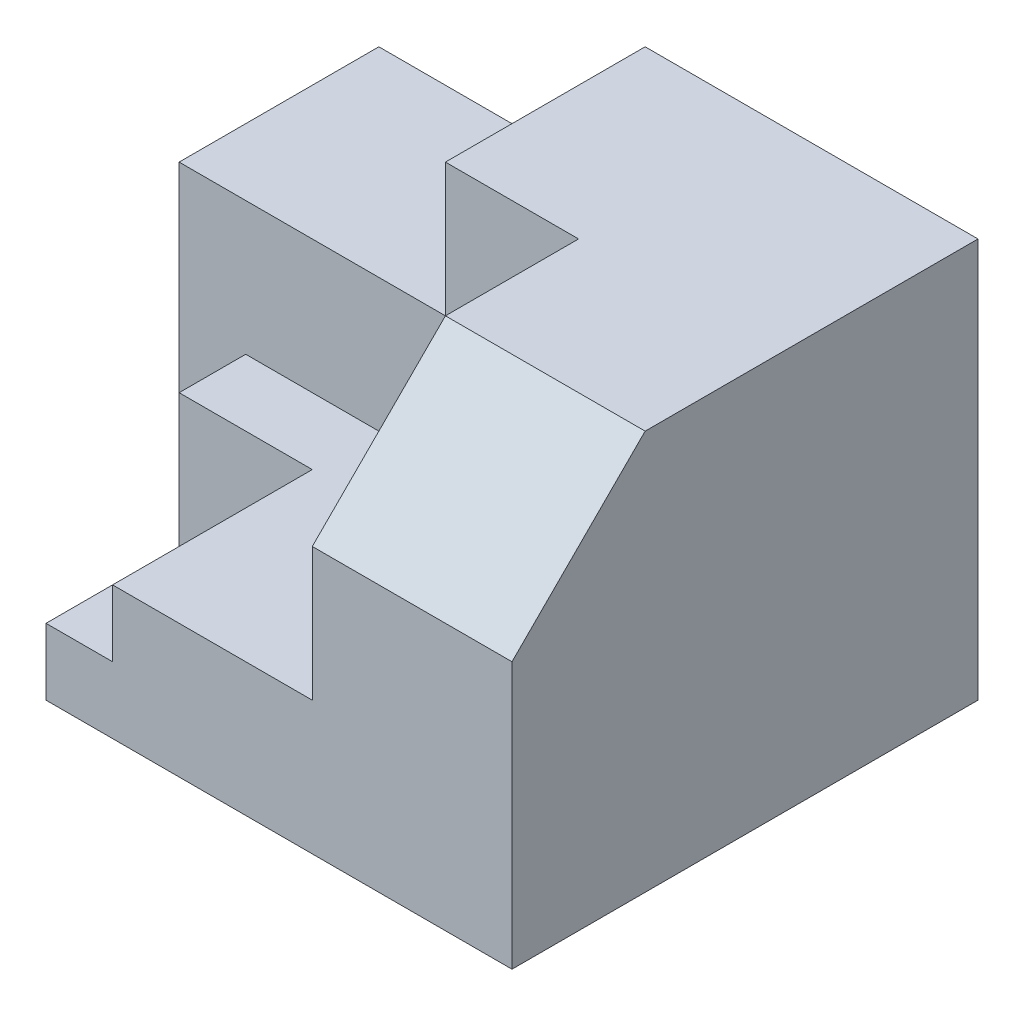
from build123d import *

# Parameters (mm, degrees)
SKETCH1_W           = 90
SKETCH1_H           = 70
BOSS_EXTRUDE1_DEPTH = 60
SKETCH2_W           = 60
SKETCH2_H           = 40
CUT_EXTRUDE1_DEPTH  = 40
SKETCH3_W           = 30
SKETCH3_H           = 30
CUT_EXTRUDE2_DEPTH  = 10
SKETCH4_W           = 30
SKETCH4_H           = 10
CUT_EXTRUDE3_DEPTH  = 20
SKETCH5_W           = 10
SKETCH5_H           = 20
CUT_EXTRUDE4_DEPTH  = 10
SKETCH7_W           = 40
SKETCH7_H           = 30
CUT_EXTRUDE5_DEPTH  = 20
CHAMFER1_SIZE       = 20


with BuildPart() as part:
    # Sketch1 → Boss-Extrude1 (new body)
    with BuildSketch(Plane(origin=(0, 0, 0), x_dir=(1, 0, 0), z_dir=(0, 1, 0))):
        with Locations((45, 35)):
            Rectangle(SKETCH1_W, SKETCH1_H)
    extrude(amount=BOSS_EXTRUDE1_DEPTH)

    # Sketch2 → Cut-Extrude1 (cut)
    with BuildSketch(Plane(origin=(0, 60, 0), x_dir=(1, 0, 0), z_dir=(0, 1, 0))):
        with Locations((30, 20)):
            Rectangle(SKETCH2_W, SKETCH2_H)
    extrude(amount=-CUT_EXTRUDE1_DEPTH, mode=Mode.SUBTRACT)

    # Sketch3 → Cut-Extrude2 (cut)
    with BuildSketch(Plane(origin=(0, 20, 0), x_dir=(1, 0, 0), z_dir=(0, 1, 0))):
        with Locations((15, 15)):
            Rectangle(SKETCH3_W, SKETCH3_H)
    extrude(amount=-CUT_EXTRUDE2_DEPTH, mode=Mode.SUBTRACT)

    # Sketch4 → Cut-Extrude3 (cut)
    with BuildSketch(Plane.ZY):
        with Locations((-15, 5)):
            Rectangle(SKETCH4_W, SKETCH4_H)
    extrude(amount=-CUT_EXTRUDE3_DEPTH, mode=Mode.SUBTRACT)

    # Sketch5 → Cut-Extrude4 (cut)
    with BuildSketch(Plane.ZY):
        with Locations((-35, 10)):
            Rectangle(SKETCH5_W, SKETCH5_H)
    extrude(amount=-CUT_EXTRUDE4_DEPTH, mode=Mode.SUBTRACT)

    # Sketch7 → Cut-Extrude5 (cut)
    with BuildSketch(Plane(origin=(0, 60, 0), x_dir=(1, 0, 0), z_dir=(0, 1, 0))):
        with Locations((20, 55)):
            Rectangle(SKETCH7_W, SKETCH7_H)
    extrude(amount=-CUT_EXTRUDE5_DEPTH, mode=Mode.SUBTRACT)

    # Chamfer1
    chamfer1_edges = [part.edges().sort_by_distance(p)[0] for p in [
        (75, 60, 0),
    ]]
    chamfer(chamfer1_edges, length=CHAMFER1_SIZE)


solid = part.part
